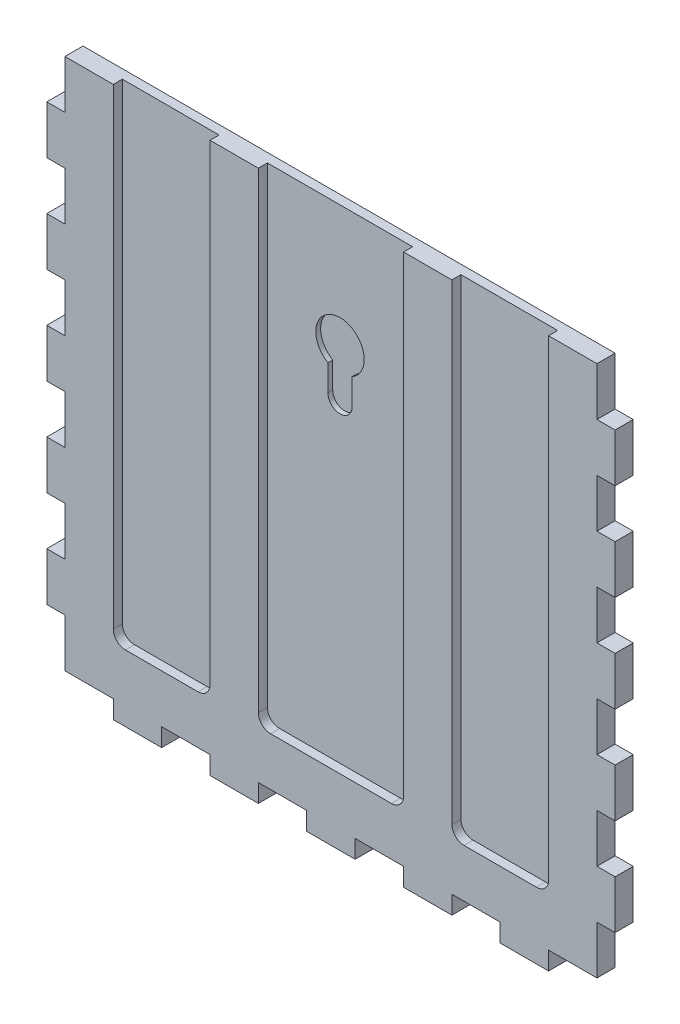
from build123d import *

# Parameters (mm, degrees)
SKETCH2_W               = 279.4
SKETCH2_H               = 279.4
BOSS_EXTRUDE1_DEPTH     = 9.525
SKETCH4_W               = 9.525
SKETCH4_H               = 25.4
BOSS_EXTRUDE3_DEPTH     = 9.525
LPATTERN2_COUNT         = 5
LPATTERN2_PITCH         = 50.8
MIRROR2_COPY_1_SKETCH_W = 9.525
MIRROR2_COPY_1_SKETCH_H = 25.4
MIRROR2_COPY_1_DEPTH    = 9.525
MIRROR2_COPY_2_SKETCH_W = 9.525
MIRROR2_COPY_2_SKETCH_H = 25.4
MIRROR2_COPY_2_DEPTH    = 9.525
MIRROR2_COPY_3_SKETCH_W = 9.525
MIRROR2_COPY_3_SKETCH_H = 25.4
MIRROR2_COPY_3_DEPTH    = 9.525
MIRROR2_COPY_4_SKETCH_W = 9.525
MIRROR2_COPY_4_SKETCH_H = 25.4
MIRROR2_COPY_4_DEPTH    = 9.525
SKETCH5_W               = 25.4
SKETCH5_H               = 9.525
BOSS_EXTRUDE4_DEPTH     = 9.525
LPATTERN3_COUNT         = 5
LPATTERN3_PITCH         = 50.8
SKETCH6_W               = 76.2
SKETCH6_H               = 254
SKETCH6_W_2             = 50.8
CUT_EXTRUDE1_DEPTH      = 4.7625
FILLET1_R               = 6.35
CUT_EXTRUDE2_DEPTH      = 2.54


with BuildPart() as part:
    # Sketch2 → Boss-Extrude1 (new body)
    with BuildSketch(Plane.XY):
        Rectangle(SKETCH2_W, SKETCH2_H)
    extrude(amount=BOSS_EXTRUDE1_DEPTH)

    # Sketch4 → Boss-Extrude3 (add)
    with BuildSketch(Plane(origin=(139.7, 0, 0), x_dir=(0, 0, -1), z_dir=(1, 0, 0))):
        with Locations((-4.7625, -101.6)):
            Rectangle(SKETCH4_W, SKETCH4_H)
    boss_extrude3 = extrude(amount=BOSS_EXTRUDE3_DEPTH)

    # LPattern2: Boss-Extrude3 ×5
    with Locations(*[(0, i * LPATTERN2_PITCH, 0) for i in range(1, LPATTERN2_COUNT)]):
        add(boss_extrude3)

    # Mirror2: Boss-Extrude3 across plane
    add(boss_extrude3.mirror(Plane(origin=(0, 0, 0), x_dir=(0, 0, 1), z_dir=(1, 0, 0))))

    # Mirror2 copy 1 sketch → Mirror2 copy 1 (add)
    with BuildSketch(Plane(origin=(-139.7, 50.8, 0), x_dir=(0, 0, -1), z_dir=(-1, 0, 0))):
        with Locations((-4.7625, 101.6)):
            Rectangle(MIRROR2_COPY_1_SKETCH_W, MIRROR2_COPY_1_SKETCH_H)
    extrude(amount=MIRROR2_COPY_1_DEPTH)

    # Mirror2 copy 2 sketch → Mirror2 copy 2 (add)
    with BuildSketch(Plane(origin=(-139.7, 101.6, 0), x_dir=(0, 0, -1), z_dir=(-1, 0, 0))):
        with Locations((-4.7625, 101.6)):
            Rectangle(MIRROR2_COPY_2_SKETCH_W, MIRROR2_COPY_2_SKETCH_H)
    extrude(amount=MIRROR2_COPY_2_DEPTH)

    # Mirror2 copy 3 sketch → Mirror2 copy 3 (add)
    with BuildSketch(Plane(origin=(-139.7, 152.4, 0), x_dir=(0, 0, -1), z_dir=(-1, 0, 0))):
        with Locations((-4.7625, 101.6)):
            Rectangle(MIRROR2_COPY_3_SKETCH_W, MIRROR2_COPY_3_SKETCH_H)
    extrude(amount=MIRROR2_COPY_3_DEPTH)

    # Mirror2 copy 4 sketch → Mirror2 copy 4 (add)
    with BuildSketch(Plane(origin=(-139.7, 203.2, 0), x_dir=(0, 0, -1), z_dir=(-1, 0, 0))):
        with Locations((-4.7625, 101.6)):
            Rectangle(MIRROR2_COPY_4_SKETCH_W, MIRROR2_COPY_4_SKETCH_H)
    extrude(amount=MIRROR2_COPY_4_DEPTH)

    # Sketch5 → Boss-Extrude4 (add)
    with BuildSketch(Plane.XZ.offset(139.7)):
        with Locations((-101.6, 4.7625)):
            Rectangle(SKETCH5_W, SKETCH5_H)
    boss_extrude4 = extrude(amount=BOSS_EXTRUDE4_DEPTH)

    # LPattern3: Boss-Extrude4 ×5
    with Locations(*[(i * LPATTERN3_PITCH, 0, 0) for i in range(1, LPATTERN3_COUNT)]):
        add(boss_extrude4)

    # Sketch6 → Cut-Extrude1 (cut)
    with BuildSketch(Plane.XY.offset(9.525)):
        with Locations((0, 12.7)):
            Rectangle(SKETCH6_W, SKETCH6_H)
        with Locations((-88.9, 12.7)):
            Rectangle(SKETCH6_W_2, SKETCH6_H)
        with Locations((88.9, 12.7)):
            Rectangle(SKETCH6_W_2, SKETCH6_H)
    extrude(amount=-CUT_EXTRUDE1_DEPTH, mode=Mode.SUBTRACT)

    # Fillet1
    fillet1_edges = [part.edges().sort_by_distance(p)[0] for p in [
        (63.5, -114.3, 7.14375),
        (114.3, -114.3, 7.14375),
        (-114.3, -114.3, 7.14375),
        (-63.5, -114.3, 7.14375),
        (-38.1, -114.3, 7.14375),
        (38.1, -114.3, 7.14375),
    ]]
    fillet(fillet1_edges, radius=FILLET1_R)

    # Sketch7 → Cut-Extrude2 (cut)
    with BuildSketch(Plane.XY.offset(4.7625)):
        with BuildLine():
            Line((6.35, 64.711297153), (6.35, 51.001361114))
            ThreePointArc((6.35, 51.001361114), (0, 44.651361114), (-6.35, 51.001361114))
            Line((-6.35, 51.001361114), (-6.35, 64.711297153))
            ThreePointArc((-6.35, 64.711297153), (0, 88.409819781), (6.35, 64.711297153))
        make_face()
    extrude(amount=-CUT_EXTRUDE2_DEPTH, mode=Mode.SUBTRACT)


solid = part.part
